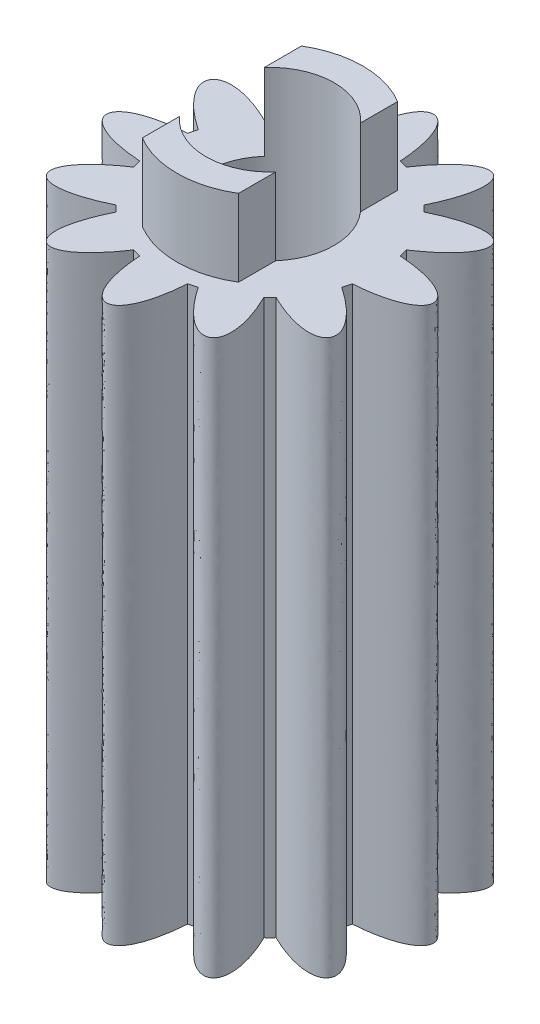
from build123d import *

# Parameters (mm, degrees)
SKETCH1_R           = 3.4
BOSS_EXTRUDE1_DEPTH = 17.3
SKETCH4_R           = 2.9
BOSS_EXTRUDE2_DEPTH = 2.4
SKETCH2_R           = 2
CUT_EXTRUDE2_DEPTH  = 19.7
SKETCH5_W           = 2
SKETCH5_H           = 12
CUT_EXTRUDE3_DEPTH  = 2.4


with BuildPart() as part:
    # Sketch1 → Boss-Extrude1 (new body)
    with BuildSketch(Plane(origin=(0, 0, 0), x_dir=(1, 0, 0), z_dir=(0, 1, 0))):
        Circle(SKETCH1_R)
        with BuildLine():
            ThreePointArc((-3.31624788, -0.75), (-3.4, 0), (-3.31624788, 0.75))
            add(Edge.make_bspline(
                [(-3.31624788, -0.75), (-5.69458404, -0.583333333), (-5.69458404, 0.583333333), (-3.31624788, 0.75)],
                knots=[0, 0, 0, 0, 1, 1, 1, 1], degree=3))
        make_face()
        with BuildLine():
            add(Edge.make_bspline(
                [(-2.496954909, -2.307642993), (-4.639987776, -3.352473506), (-5.223321109, -2.342110534), (-3.246954909, -1.008604887)],
                knots=[0, 0, 0, 0, 1, 1, 1, 1], degree=3))
            ThreePointArc((-2.496954909, -2.307642993), (-2.944486373, -1.7), (-3.246954909, -1.008604887))
        make_face()
        with BuildLine():
            add(Edge.make_bspline(
                [(-1.008604887, -3.246954909), (-2.342110534, -5.223321109), (-3.352473506, -4.639987776), (-2.307642993, -2.496954909)],
                knots=[0, 0, 0, 0, 1, 1, 1, 1], degree=3))
            ThreePointArc((-1.008604887, -3.246954909), (-1.7, -2.944486373), (-2.307642993, -2.496954909))
        make_face()
        with BuildLine():
            add(Edge.make_bspline(
                [(0.75, -3.31624788), (0.583333333, -5.69458404), (-0.583333333, -5.69458404), (-0.75, -3.31624788)],
                knots=[0, 0, 0, 0, 1, 1, 1, 1], degree=3))
            ThreePointArc((0.75, -3.31624788), (0, -3.4), (-0.75, -3.31624788))
        make_face()
        with BuildLine():
            add(Edge.make_bspline(
                [(2.307642993, -2.496954909), (3.352473506, -4.639987776), (2.342110534, -5.223321109), (1.008604887, -3.246954909)],
                knots=[0, 0, 0, 0, 1, 1, 1, 1], degree=3))
            ThreePointArc((2.307642993, -2.496954909), (1.7, -2.944486373), (1.008604887, -3.246954909))
        make_face()
        with BuildLine():
            add(Edge.make_bspline(
                [(3.246954909, -1.008604887), (5.223321109, -2.342110534), (4.639987776, -3.352473506), (2.496954909, -2.307642993)],
                knots=[0, 0, 0, 0, 1, 1, 1, 1], degree=3))
            ThreePointArc((3.246954909, -1.008604887), (2.944486373, -1.7), (2.496954909, -2.307642993))
        make_face()
        with BuildLine():
            ThreePointArc((3.31624788, 0.75), (3.378997099, 0.377330895), (3.4, 0))
            ThreePointArc((3.4, 0), (3.378997099, -0.377330895), (3.31624788, -0.75))
            add(Edge.make_bspline(
                [(3.31624788, 0.75), (5.69458404, 0.583333333), (5.69458404, -0.583333333), (3.31624788, -0.75)],
                knots=[0, 0, 0, 0, 1, 1, 1, 1], degree=3))
        make_face()
        with BuildLine():
            ThreePointArc((2.496954909, 2.307642993), (2.944486373, 1.7), (3.246954909, 1.008604887))
            add(Edge.make_bspline(
                [(2.496954909, 2.307642993), (4.639987776, 3.352473506), (5.223321109, 2.342110534), (3.246954909, 1.008604887)],
                knots=[0, 0, 0, 0, 1, 1, 1, 1], degree=3))
        make_face()
        with BuildLine():
            ThreePointArc((1.008604887, 3.246954909), (1.7, 2.944486373), (2.307642993, 2.496954909))
            add(Edge.make_bspline(
                [(1.008604887, 3.246954909), (2.342110534, 5.223321109), (3.352473506, 4.639987776), (2.307642993, 2.496954909)],
                knots=[0, 0, 0, 0, 1, 1, 1, 1], degree=3))
        make_face()
        with BuildLine():
            ThreePointArc((-3.246954909, 1.008604887), (-2.944486373, 1.7), (-2.496954909, 2.307642993))
            add(Edge.make_bspline(
                [(-3.246954909, 1.008604887), (-5.223321109, 2.342110534), (-4.639987776, 3.352473506), (-2.496954909, 2.307642993)],
                knots=[0, 0, 0, 0, 1, 1, 1, 1], degree=3))
        make_face()
        with BuildLine():
            ThreePointArc((-2.307642993, 2.496954909), (-1.7, 2.944486373), (-1.008604887, 3.246954909))
            add(Edge.make_bspline(
                [(-2.307642993, 2.496954909), (-3.352473506, 4.639987776), (-2.342110534, 5.223321109), (-1.008604887, 3.246954909)],
                knots=[0, 0, 0, 0, 1, 1, 1, 1], degree=3))
        make_face()
        with BuildLine():
            ThreePointArc((-0.75, 3.31624788), (0, 3.4), (0.75, 3.31624788))
            add(Edge.make_bspline(
                [(-0.75, 3.31624788), (-0.583333333, 5.69458404), (0.583333333, 5.69458404), (0.75, 3.31624788)],
                knots=[0, 0, 0, 0, 1, 1, 1, 1], degree=3))
        make_face()
    extrude(amount=BOSS_EXTRUDE1_DEPTH)

    # Sketch4 → Boss-Extrude2 (add)
    with BuildSketch(Plane(origin=(0, 17.3, 0), x_dir=(1, 0, 0), z_dir=(0, 1, 0))):
        Circle(SKETCH4_R)
    extrude(amount=BOSS_EXTRUDE2_DEPTH)

    # Sketch2 → Cut-Extrude2 (cut)
    with BuildSketch(Plane.XZ):
        Circle(SKETCH2_R)
    extrude(amount=-CUT_EXTRUDE2_DEPTH, mode=Mode.SUBTRACT)

    # Sketch5 → Cut-Extrude3 (cut)
    with BuildSketch(Plane(origin=(0, 17.3, 0), x_dir=(1, 0, 0), z_dir=(0, 1, 0))):
        with Locations((2.5, 0)):
            Rectangle(SKETCH5_W, SKETCH5_H)
        with Locations((-2.5, 0)):
            Rectangle(SKETCH5_W, SKETCH5_H)
    extrude(amount=CUT_EXTRUDE3_DEPTH, mode=Mode.SUBTRACT)


solid = part.part
